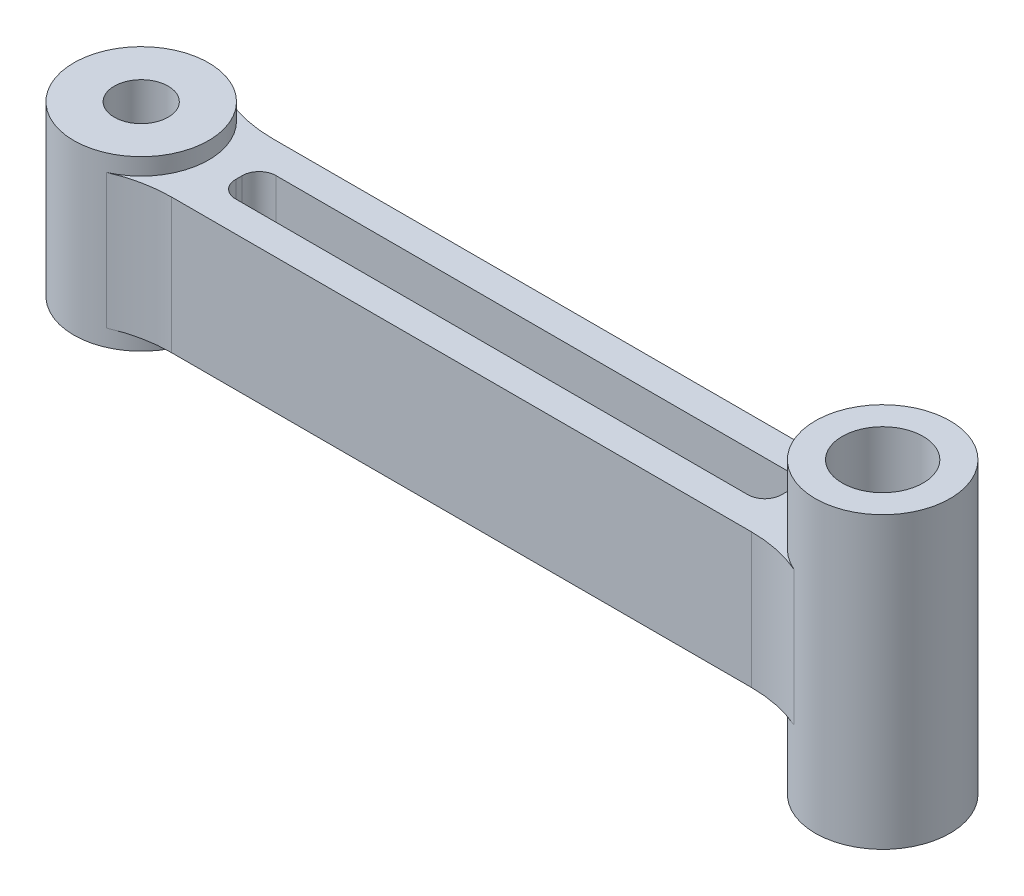
from build123d import *

# Parameters (mm, degrees)
SKETCH2_R           = 10
SKETCH2_R_2         = 6
BOSS_EXTRUDE1_DEPTH = 21.5
BOSS_EXTRUDE2_DEPTH = 10
CUT_EXTRUDE1_DEPTH  = 6.25
FILLET1_R           = 20
FILLET2_R           = 2.5
MOVE_FACE1_BY       = 9
MOVE_FACE2_BY       = 9
MOVE_FACE3_BY       = 2


with BuildPart() as part:
    # Sketch2 → Boss-Extrude1 (new, symmetric)
    with BuildSketch(Plane(origin=(0, 0, 0), x_dir=(1, 0, 0), z_dir=(0, 1, 0))):
        with Locations(Location((-55, 7.5, 0), (0, 0, 270))):
            Circle(SKETCH2_R)
        with Locations(Location((-55, 7.5, 0), (0, 0, 270))):
            Circle(SKETCH2_R_2, mode=Mode.SUBTRACT)
    extrude(amount=BOSS_EXTRUDE1_DEPTH, both=True)

    # Sketch2_3 → Boss-Extrude2 (add, symmetric)
    with BuildSketch(Plane(origin=(0, 0, 0), x_dir=(1, 0, 0), z_dir=(0, 1, 0))):
        with BuildLine():
            Line((0, 0), (0, 7.5))
            Line((0, 7.5), (-45, 7.5))
            ThreePointArc((-45, 7.5), (-45.885621722, 3.385621722), (-48.385621722, 0))
            Line((-48.385621722, 0), (0, 0))
        make_face()
        with BuildLine():
            Line((-45, 7.5), (0, 7.5))
            Line((0, 7.5), (0, 15))
            Line((0, 15), (-48.385621722, 15))
            ThreePointArc((-48.385621722, 15), (-45.885621722, 11.614378278), (-45, 7.5))
        make_face()
    extrude(amount=BOSS_EXTRUDE2_DEPTH, both=True)

    # Mirror1: part across plane


with BuildPart() as part_1:
    add(part.part)
    add(part.part.mirror(Plane(origin=(0, 10, 0), x_dir=(0, 0, 1), z_dir=(-1, 0, 0))))

    # Sketch3 → Cut-Extrude1 (cut)
    with BuildSketch(Plane(origin=(0, 10, 0), x_dir=(1, 0, 0), z_dir=(0, 1, 0))):
        with BuildLine():
            Line((40.813739041, 10.5), (-40.813739041, 10.5))
            ThreePointArc((-40.813739041, 10.5), (-40.5, 7.5), (-40.813739041, 4.5))
            Line((-40.813739041, 4.5), (40.813739041, 4.5))
            ThreePointArc((40.813739041, 4.5), (40.5, 7.5), (40.813739041, 10.5))
        make_face()
    cut_extrude1 = extrude(amount=-CUT_EXTRUDE1_DEPTH, mode=Mode.SUBTRACT)

    # Mirror2: Cut-Extrude1 across plane
    add(cut_extrude1.mirror(Plane.ZX), mode=Mode.SUBTRACT)

    # Fillet1
    fillet1_edges = [part_1.edges().sort_by_distance(p)[0] for p in [
        (-48.385621722, 0, -15),
        (-48.385621722, 0, 0),
        (48.385621722, 0, 0),
        (48.385621722, 0, -15),
    ]]
    fillet(fillet1_edges, radius=FILLET1_R)

    # Fillet2
    fillet2_edges = [part_1.edges().sort_by_distance(p)[0] for p in [
        (-40.813739041, 6.875, -4.5),
        (-40.813739041, 6.875, -10.5),
        (40.813739041, 6.875, -10.5),
        (40.813739041, 6.875, -4.5),
        (-40.813739041, -6.875, -10.5),
        (-40.813739041, -6.875, -4.5),
        (40.813739041, -6.875, -4.5),
        (40.813739041, -6.875, -10.5),
    ]]
    fillet(fillet2_edges, radius=FILLET2_R)

    # Move Face1: a face moved inward by 9.0
    extrude(part_1.faces().sort_by_distance((-55, 21.5, 0.5))[0], amount=MOVE_FACE1_BY, dir=(0, -1, 0), mode=Mode.SUBTRACT)

    # Move Face2: a face moved inward by 9.0
    extrude(part_1.faces().sort_by_distance((-55, -21.5, 0.5))[0], amount=MOVE_FACE2_BY, dir=(0, 1, 0), mode=Mode.SUBTRACT)

    # Move Face3: a curved face moved outward by 2.0
    add(Solid.thicken(part_1.faces().sort_by_distance((-55, 0, -13.5))[0], MOVE_FACE3_BY))


solid = part_1.part
